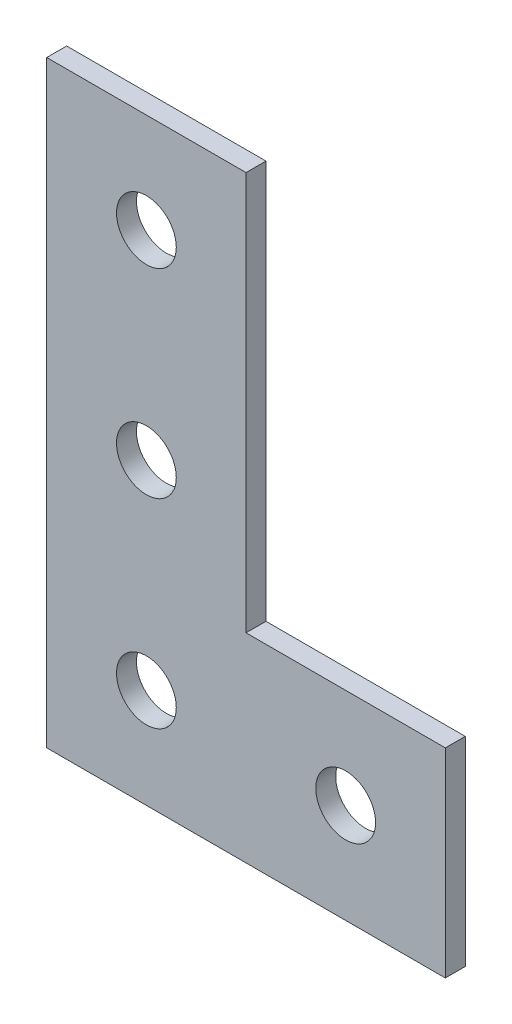
from build123d import *

# Parameters (mm, degrees)
BOSS_EXTRU_1_DEPTH      = 1
ESQUISSE2_R             = 1.5
ENL_V_MAT_EXTRU_1_DEPTH = 2


with BuildPart() as part:
    # Esquisse1 → Boss.-Extru.1 (new body)
    with BuildSketch(Plane.XY):
        Polygon((0, 0), (20, 0), (20, 10), (10, 10), (10, 30), (0, 30), align=None)
    extrude(amount=BOSS_EXTRU_1_DEPTH)

    # Esquisse2 → Enlèv. mat.-Extru.1 (cut, through all)
    with BuildSketch(Plane.XY.offset(1)):
        with Locations((5, 5)):
            Circle(ESQUISSE2_R)
        with Locations((5, 15)):
            Circle(ESQUISSE2_R)
        with Locations((5, 25)):
            Circle(ESQUISSE2_R)
        with Locations((15, 5)):
            Circle(ESQUISSE2_R)
    extrude(amount=-ENL_V_MAT_EXTRU_1_DEPTH, mode=Mode.SUBTRACT)


solid = part.part
